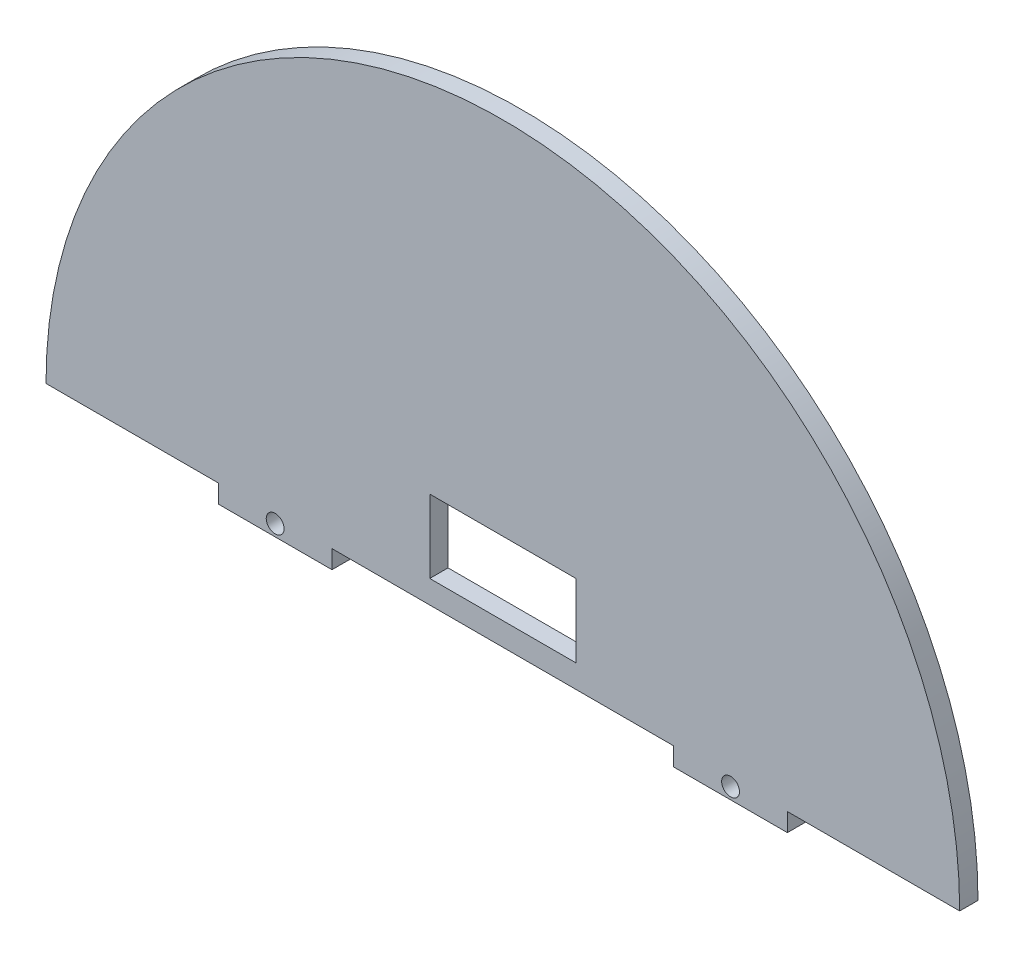
from build123d import *
from build123d.topology import SkipClean

# Parameters (mm, degrees)
SKETCH1_W           = 25.4
SKETCH1_H           = 12.7
BOSS_EXTRUDE1_DEPTH = 1.59
SKETCH1_4_R         = 1.55
CUT_EXTRUDE2_DEPTH  = 5


with BuildPart() as part:
    # Sketch1 → Boss-Extrude1 (new, symmetric)
    with BuildSketch(Plane.XY):
        with BuildLine():
            ThreePointArc((79.38, 0), (0, 79.38), (-79.38, 0))
            Line((-79.38, 0), (-49.44, 0))
            Line((-49.44, 0), (-49.44, -3.18))
            Line((-49.44, -3.18), (-29.69, -3.18))
            Line((-29.69, -3.18), (-29.69, 0))
            Line((-29.69, 0), (29.69, 0))
            Line((29.69, 0), (29.69, -3.18))
            Line((29.69, -3.18), (49.44, -3.18))
            Line((49.44, -3.18), (49.44, 0))
            Line((49.44, 0), (79.38, 0))
        make_face()
        with BuildLine():
            ThreePointArc((-40.570037313, 0), (-39.565, 0.37), (-38.559962687, 0))
            Line((-38.559962687, 0), (-40.570037313, 0))
        make_face(mode=Mode.SUBTRACT)
        with Locations((0, 10.35)):
            Rectangle(SKETCH1_W, SKETCH1_H, mode=Mode.SUBTRACT)
    extrude(amount=BOSS_EXTRUDE1_DEPTH, both=True)

    # Sketch1_4 → Cut-Extrude2 (cut, symmetric)
    with SkipClean():  # the faces are left unmerged after this step: merging them gives an invalid solid
        with BuildSketch(Plane.XY):
            with Locations((-39.565, -1.18)):
                Circle(SKETCH1_4_R)
        cut_extrude2 = extrude(amount=CUT_EXTRUDE2_DEPTH, both=True, mode=Mode.SUBTRACT)

    # Mirror1: Cut-Extrude2 across plane
    with SkipClean():  # the faces are left unmerged after this step: merging them gives an invalid solid
        add(cut_extrude2.mirror(Plane(origin=(0, 0, 0), x_dir=(0, 0, 1), z_dir=(1, 0, 0))), mode=Mode.SUBTRACT)


solid = part.part
